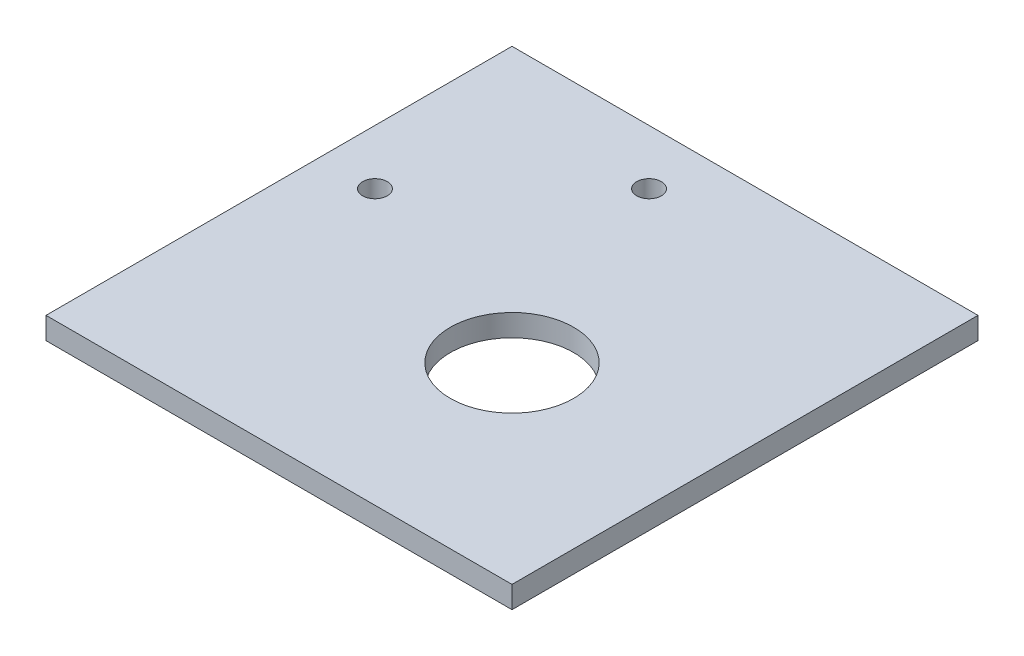
from build123d import *

# Parameters (mm, degrees)
SKETCH1_W           = 85
SKETCH1_H           = 85
SKETCH1_R           = 11.25
SKETCH1_R_2         = 2.25
BOSS_EXTRUDE1_DEPTH = 4


with BuildPart() as part:
    # Sketch1 → Boss-Extrude1 (new body)
    with BuildSketch(Plane(origin=(0, 0, 0), x_dir=(1, 0, 0), z_dir=(0, 1, 0))):
        with Locations((-7.5, 7.5)):
            Rectangle(SKETCH1_W, SKETCH1_H)
        Circle(SKETCH1_R, mode=Mode.SUBTRACT)
        with Locations((-15, 40)):
            Circle(SKETCH1_R_2, mode=Mode.SUBTRACT)
        with Locations((-40, 15)):
            Circle(SKETCH1_R_2, mode=Mode.SUBTRACT)
    extrude(amount=BOSS_EXTRUDE1_DEPTH)


solid = part.part
